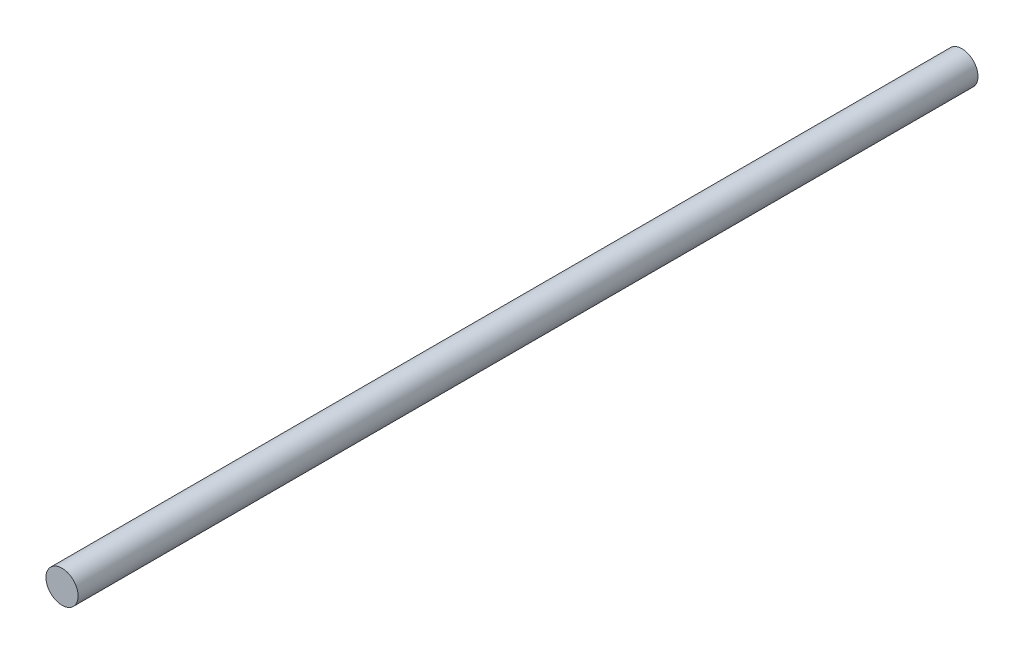
from build123d import *

# Parameters (mm, degrees)
SKETCH1_R           = 15
BOSS_EXTRUDE1_DEPTH = 840


with BuildPart() as part:
    # Sketch1 → Boss-Extrude1 (new body)
    with BuildSketch(Plane.XY):
        Circle(SKETCH1_R)
    extrude(amount=BOSS_EXTRUDE1_DEPTH)


solid = part.part
